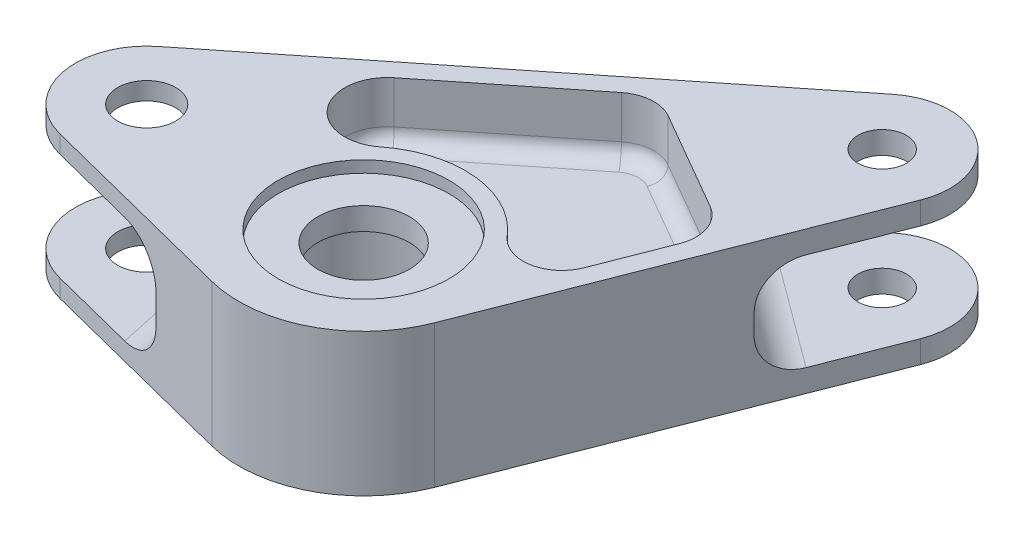
from build123d import *

# Parameters (mm, degrees)
BOSS_EXTRUDE2_DEPTH = 11.684
SKETCH3_R           = 12
CUT_EXTRUDE1_DEPTH  = 17.78
SKETCH5_R           = 4.7625
SKETCH5_R_2         = 3.96875
CUT_EXTRUDE3_DEPTH  = 24.368
SKETCH4_R           = 7.5
CUT_EXTRUDE2_DEPTH  = 24.368
CUT_EXTRUDE4_DEPTH  = 9.525
CUT_EXTRUDE5_DEPTH  = 9.525
SKETCH10_R          = 14
CUT_EXTRUDE6_DEPTH  = 1.905
CUT_EXTRUDE7_REACH  = 35.001
SKETCH12_W          = 38.1
SKETCH12_H          = 16.002
CUT_EXTRUDE8_REACH  = 32.013
SKETCH15_W          = 50.8
SKETCH15_H          = 17.5768
FILLET2_R           = 3.175
FILLET3_R           = 6.35
FILLET4_R           = 2.54
SKETCH16_R          = 17.272
CUT_EXTRUDE9_DEPTH  = 3.048


with BuildPart() as part:
    # Sketch2 → Boss-Extrude2 (new body, symmetric)
    with BuildSketch(Plane(origin=(0, 0, 0), x_dir=(1, 0, 0), z_dir=(0, 1, 0))):
        with BuildLine():
            Line((-42.844042296, 9.135566968), (24.187242381, 62.581479461))
            ThreePointArc((24.187242381, 62.581479461), (37.709893542, 62.836755255), (41.463262143, 49.842930403))
            Line((41.463262143, 49.842930403), (19.040802343, -7.451688072))
            ThreePointArc((19.040802343, -7.451688072), (9.340036317, -18.189104722), (-5.038725, -19.816434073))
            Line((-5.038725, -19.816434073), (-38.439271429, -11.323676613))
            ThreePointArc((-38.439271429, -11.323676613), (-46.982276413, -2.459157895), (-42.844042296, 9.135566968))
        make_face()
    extrude(amount=BOSS_EXTRUDE2_DEPTH, both=True)

    # Sketch3 → Cut-Extrude1 (cut)
    with BuildSketch(Plane.XZ.offset(11.684)):
        Circle(SKETCH3_R)
    extrude(amount=-CUT_EXTRUDE1_DEPTH, mode=Mode.SUBTRACT)

    # Sketch5 → Cut-Extrude3 (cut, through all)
    with BuildSketch(Plane(origin=(0, 11.684, 0), x_dir=(1, 0, 0), z_dir=(0, 1, 0))):
        with Locations((-35.56, 0)):
            Circle(SKETCH5_R)
        with Locations((31.115, 53.892760878)):
            Circle(SKETCH5_R_2)
    extrude(amount=-CUT_EXTRUDE3_DEPTH, mode=Mode.SUBTRACT)

    # Sketch4 → Cut-Extrude2 (cut, through all)
    with BuildSketch(Plane(origin=(0, 11.684, 0), x_dir=(1, 0, 0), z_dir=(0, 1, 0))):
        Circle(SKETCH4_R)
    extrude(amount=-CUT_EXTRUDE2_DEPTH, mode=Mode.SUBTRACT)

    # Sketch6 → Cut-Extrude4 (cut)
    with BuildSketch(Plane(origin=(0, 11.684, 0), x_dir=(1, 0, 0), z_dir=(0, 1, 0))):
        with BuildLine():
            Line((8.810645098, 41.106966719), (25.147527575, 31.674863223))
            ThreePointArc((25.147527575, 31.674863223), (27.965170287, 28.275776503), (27.885820228, 23.861413067))
            Line((27.885820228, 23.861413067), (23.481205903, 12.606595374))
            ThreePointArc((23.481205903, 12.606595374), (18.614262725, 8.65758593), (12.727975438, 10.810127095))
            ThreePointArc((12.727975438, 10.810127095), (1.647083767, 16.617680994), (-10.358254645, 13.098349791))
            ThreePointArc((-10.358254645, 13.098349791), (-20.167393041, 14.234267976), (-19.051094323, 24.045658467))
            Line((-19.051094323, 24.045658467), (1.676926459, 40.572687453))
            ThreePointArc((1.676926459, 40.572687453), (5.16139062, 41.939970615), (8.810645098, 41.106966719))
        make_face()
    extrude(amount=-CUT_EXTRUDE4_DEPTH, mode=Mode.SUBTRACT)

    # Sketch8 → Cut-Extrude5 (cut)
    with BuildSketch(Plane.XZ.offset(11.684)):
        with BuildLine():
            Line((25.147527575, -31.674863223), (8.810645098, -41.106966719))
            ThreePointArc((8.810645098, -41.106966719), (5.16139062, -41.939970615), (1.676926459, -40.572687453))
            Line((1.676926459, -40.572687453), (-13.415958874, -28.5387091))
            ThreePointArc((-13.415958874, -28.5387091), (-14.944664248, -20.378311947), (-7.092930176, -17.680295289))
            ThreePointArc((-7.092930176, -17.680295289), (4.120108003, -18.599118529), (13.896097136, -13.030770675))
            ThreePointArc((13.896097136, -13.030770675), (19.728139709, -11.138779489), (24.441422168, -15.060172058))
            Line((24.441422168, -15.060172058), (27.885820228, -23.861413067))
            ThreePointArc((27.885820228, -23.861413067), (27.965170287, -28.275776503), (25.147527575, -31.674863223))
        make_face()
    extrude(amount=-CUT_EXTRUDE5_DEPTH, mode=Mode.SUBTRACT)

    # Sketch10 → Cut-Extrude6 (cut)
    with BuildSketch(Plane(origin=(0, 11.684, 0), x_dir=(1, 0, 0), z_dir=(0, 1, 0))):
        Circle(SKETCH10_R)
    extrude(amount=-CUT_EXTRUDE6_DEPTH, mode=Mode.SUBTRACT)

    # Sketch12 → Cut-Extrude7 (cut, up to next)
    with BuildSketch(Plane(origin=(26.337597963, 0, -35.719049385), x_dir=(0.804858887, 0, 0.593466235), z_dir=(-0.593466235, 0, 0.804858887)), mode=Mode.PRIVATE) as cut_extrude7_sk1:
        with Locations((-6.94034966, 0)):
            Rectangle(SKETCH12_W, SKETCH12_H)
    cut_extrude7_tool1 = extrude(cut_extrude7_sk1.sketch, amount=-CUT_EXTRUDE7_REACH, mode=Mode.PRIVATE) & part.part
    add(cut_extrude7_tool1.solids().sort_by_distance((20.751596, 0, -39.837913))[0], mode=Mode.SUBTRACT)

    # Sketch15 → Cut-Extrude8 (cut, up to next)
    with BuildSketch(Plane(origin=(-20.01728519, 0, 4.309619478), x_dir=(0.210472261, 0, 0.97759983), z_dir=(-0.97759983, 0, 0.210472261)), mode=Mode.PRIVATE) as cut_extrude8_sk1:
        with Locations((-7.484393594, 0)):
            Rectangle(SKETCH15_W, SKETCH15_H)
    cut_extrude8_tool1 = extrude(cut_extrude8_sk1.sketch, amount=CUT_EXTRUDE8_REACH, mode=Mode.PRIVATE) & part.part
    add(cut_extrude8_tool1.solids().sort_by_distance((-21.592542, 0, -3.007122))[0], mode=Mode.SUBTRACT)

    # Fillet2
    fillet2_edges = [part.edges().sort_by_distance(p)[0] for p in [
        (19.728139709, -2.159, -11.138779489),
        (26.163621198, -2.159, -19.460792562),
        (27.965170287, -2.159, -28.275776503),
        (16.979086336, -2.159, -36.390914971),
        (5.16139062, -2.159, -41.939970615),
        (-5.869516208, -2.159, -34.555698277),
        (-14.944664248, -2.159, -20.378311947),
        (4.120108003, -2.159, -18.599118529),
    ]]
    fillet(fillet2_edges, radius=FILLET2_R)

    # Fillet3
    fillet3_edges = [part.edges().sort_by_distance(p)[0] for p in [
        (20.751595863, -8.001, -39.83791257),
        (20.751595863, 8.001, -39.83791257),
        (-21.59254243, -8.7884, -3.007122426),
        (-21.59254243, 8.7884, -3.007122426),
    ]]
    fillet(fillet3_edges, radius=FILLET3_R)

    # Fillet4
    fillet4_edges = [part.edges().sort_by_distance(p)[0] for p in [
        (-20.167393041, 2.159, -14.234267976),
        (-8.687083932, 2.159, -32.30917296),
        (5.16139062, 2.159, -41.939970615),
        (16.979086336, 2.159, -36.390914971),
        (27.965170287, 2.159, -28.275776503),
        (25.683513065, 2.159, -18.234004221),
        (18.614262725, 2.159, -8.65758593),
        (1.647083767, 2.159, -16.617680994),
    ]]
    fillet(fillet4_edges, radius=FILLET4_R)

    # Sketch16 → Cut-Extrude9 (cut)
    with BuildSketch(Plane.XZ.offset(11.684)):
        Circle(SKETCH16_R)
    extrude(amount=-CUT_EXTRUDE9_DEPTH, mode=Mode.SUBTRACT)


solid = part.part
